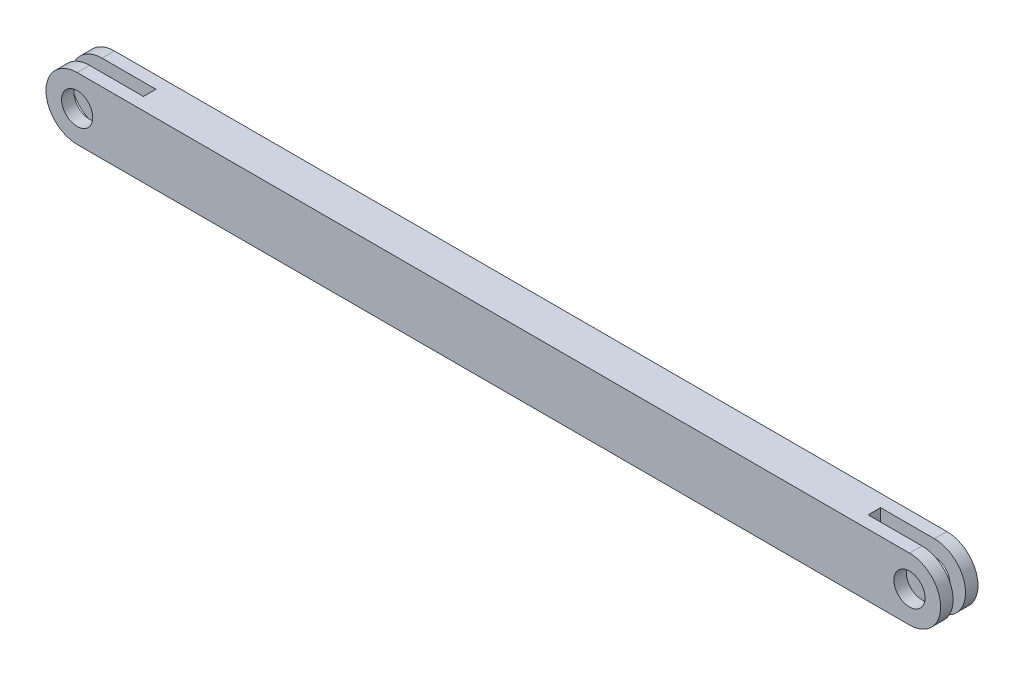
from build123d import *

# Parameters (mm, degrees)
SKETCH19_W               = 115
SKETCH19_H               = 10
BOSS_EXTRUDE4_DEPTH      = 3
SKETCH21_R               = 2.5
BOSS_EXTRUDE13_DEPTH     = 2
MIRROR15_COPY_1_SKETCH_W = 115
MIRROR15_COPY_1_SKETCH_H = 10
MIRROR15_COPY_1_DEPTH    = 3
MIRROR15_COPY_2_SKETCH_R = 2.5
MIRROR15_COPY_2_DEPTH    = 2


with BuildPart() as part:
    # Sketch19 → Boss-Extrude4 (new body, symmetric)
    with BuildSketch(Plane.XY):
        with Locations((-0.678145843, -0.350765091)):
            Rectangle(SKETCH19_W, SKETCH19_H)
    boss_extrude4 = extrude(amount=BOSS_EXTRUDE4_DEPTH, both=True)

    # Sketch21 → Boss-Extrude13 (add)
    with BuildSketch(Plane.XY.offset(3)):
        with BuildLine():
            ThreePointArc((66.821854157, 4.649234909), (71.821854157, -0.350765091), (66.821854157, -5.350765091))
            Line((66.821854157, -5.350765091), (56.821854157, -5.350765091))
            Line((56.821854157, -5.350765091), (56.821854157, 4.649234909))
            Line((56.821854157, 4.649234909), (66.821854157, 4.649234909))
        make_face()
        with Locations((66.821854157, -0.350765091)):
            Circle(SKETCH21_R, mode=Mode.SUBTRACT)
    boss_extrude13 = extrude(amount=-BOSS_EXTRUDE13_DEPTH)

    # Mirror14: Boss-Extrude4, Boss-Extrude13 across plane
    add(boss_extrude4.mirror(Plane.XY))
    add(boss_extrude13.mirror(Plane.XY))

    # Mirror15: Boss-Extrude4, Boss-Extrude13 across plane
    add(boss_extrude4.mirror(Plane(origin=(0, 0, 0), x_dir=(0, 0, 1), z_dir=(1, 0, 0))))
    add(boss_extrude13.mirror(Plane(origin=(0, 0, 0), x_dir=(0, 0, 1), z_dir=(1, 0, 0))))

    # Mirror15 copy 1 sketch → Mirror15 copy 1 (add, symmetric)
    with BuildSketch(Plane(origin=(0, 0, 0), x_dir=(-1, 0, 0), z_dir=(0, 0, -1))):
        with Locations((-0.678145843, -0.350765091)):
            Rectangle(MIRROR15_COPY_1_SKETCH_W, MIRROR15_COPY_1_SKETCH_H)
    extrude(amount=MIRROR15_COPY_1_DEPTH, both=True)

    # Mirror15 copy 2 sketch → Mirror15 copy 2 (add)
    with BuildSketch(Plane(origin=(0, 0, -3), x_dir=(-1, 0, 0), z_dir=(0, 0, -1))):
        with BuildLine():
            ThreePointArc((66.821854157, 4.649234909), (71.821854157, -0.350765091), (66.821854157, -5.350765091))
            Line((66.821854157, -5.350765091), (56.821854157, -5.350765091))
            Line((56.821854157, -5.350765091), (56.821854157, 4.649234909))
            Line((56.821854157, 4.649234909), (66.821854157, 4.649234909))
        make_face()
        with Locations((66.821854157, -0.350765091)):
            Circle(MIRROR15_COPY_2_SKETCH_R, mode=Mode.SUBTRACT)
    extrude(amount=-MIRROR15_COPY_2_DEPTH)


solid = part.part
